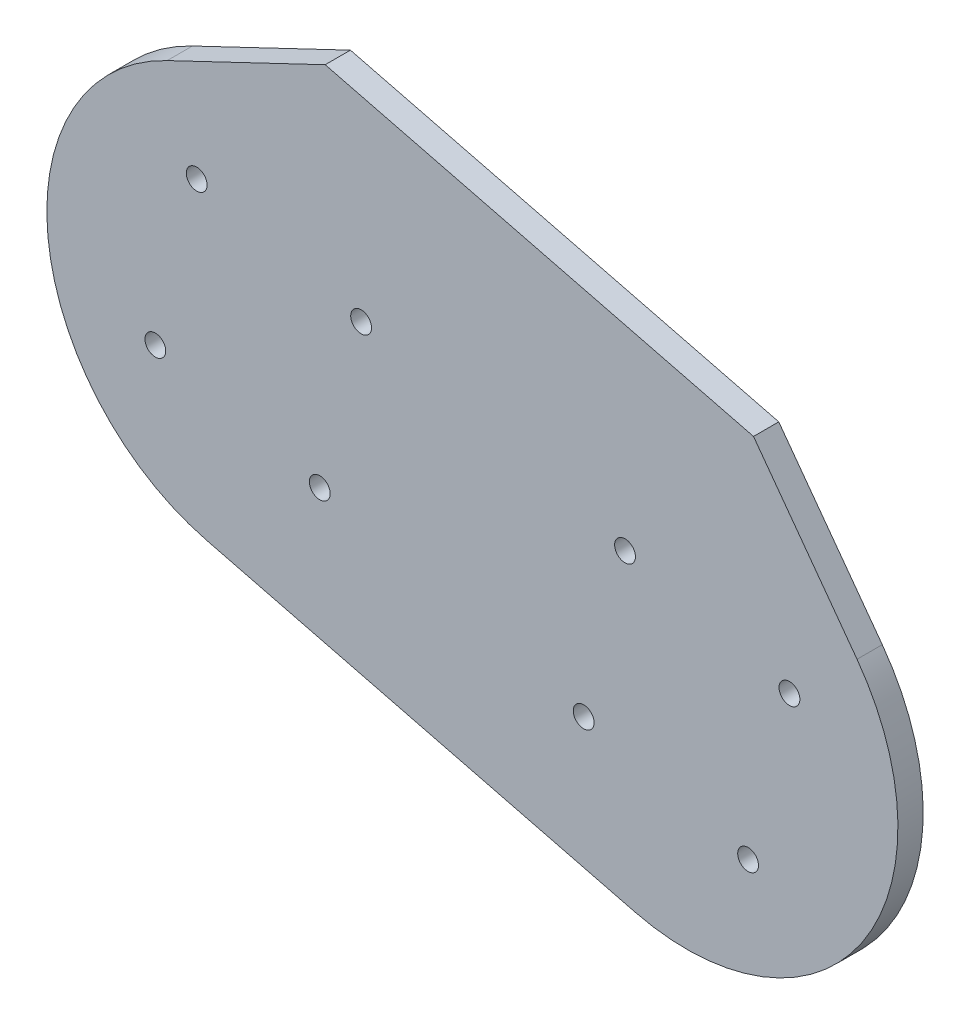
from build123d import *

# Parameters (mm, degrees)
SKETCH_1_R      = 1.65
EXTRUDE_1_DEPTH = 4


with BuildPart() as part:
    # 草图1 → 凸台-拉伸1 (new body)
    with BuildSketch(Plane.XY):
        with BuildLine():
            Line((356.978840025, -329.388705272), (424.86396809, -346.465279506))
            ThreePointArc((424.86396809, -346.465279506), (460.82942454, -332.680172491), (460.054173141, -294.171183692))
            Line((460.054173141, -294.171183692), (443.648199748, -271.791638634))
            Line((443.648199748, -271.791638634), (375.763071682, -254.7150644))
            Line((375.763071682, -254.7150644), (350.72066994, -266.668227789))
            ThreePointArc((350.72066994, -266.668227789), (331.816725216, -300.226894433), (356.978840025, -329.388705272))
        make_face()
        with Locations((355.399566463, -280.594209399)):
            Circle(SKETCH_1_R, mode=Mode.SUBTRACT)
        with Locations((381.457813707, -287.149188467)):
            Circle(SKETCH_1_R, mode=Mode.SUBTRACT)
        with Locations((348.844587395, -306.652456643)):
            Circle(SKETCH_1_R, mode=Mode.SUBTRACT)
        with Locations((374.902834639, -313.207435711)):
            Circle(SKETCH_1_R, mode=Mode.SUBTRACT)
        with Locations((423.284694528, -297.670783633)):
            Circle(SKETCH_1_R, mode=Mode.SUBTRACT)
        with Locations((449.342941772, -304.225762701)):
            Circle(SKETCH_1_R, mode=Mode.SUBTRACT)
        with Locations((416.729715461, -323.729030877)):
            Circle(SKETCH_1_R, mode=Mode.SUBTRACT)
        with Locations((442.787962705, -330.284009945)):
            Circle(SKETCH_1_R, mode=Mode.SUBTRACT)
    extrude(amount=EXTRUDE_1_DEPTH)


solid = part.part
